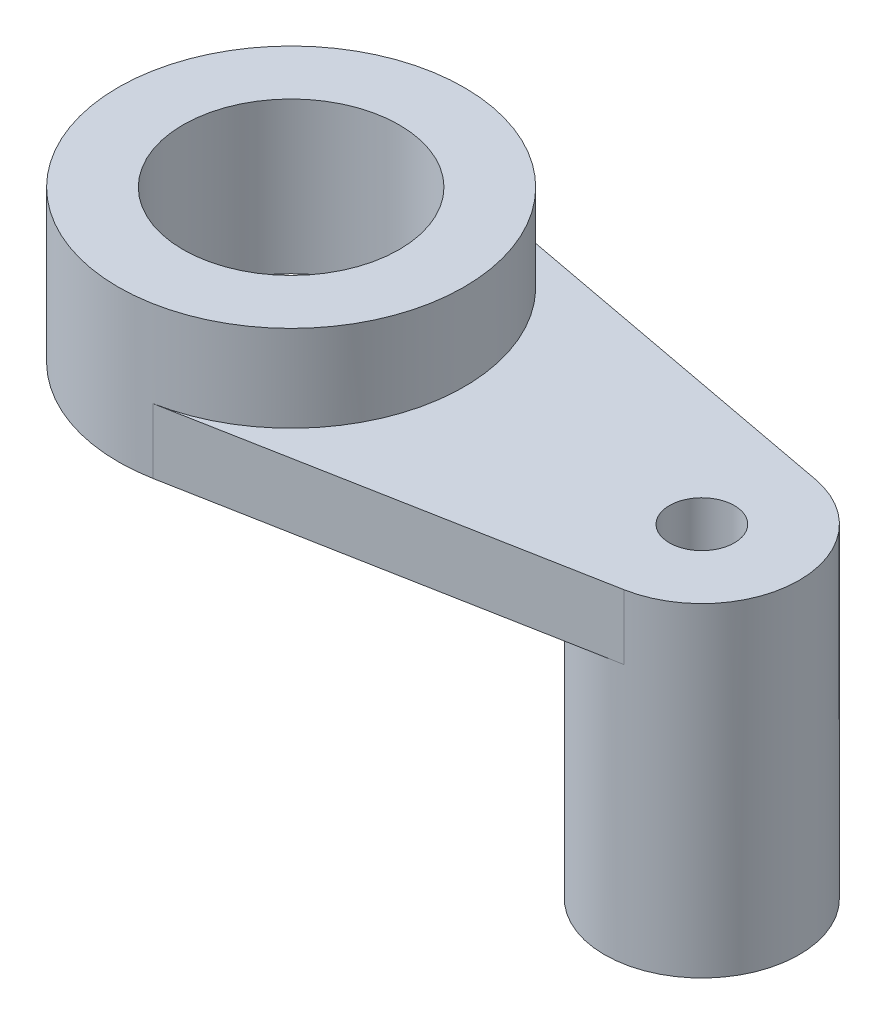
from build123d import *

# Parameters (mm, degrees)
SKETCH1_R           = 16
SKETCH1_R_2         = 10
BOSS_EXTRUDE1_DEPTH = 14
SKETCH1_3_R         = 9
SKETCH1_3_R_2       = 3
BOSS_EXTRUDE2_DEPTH = 6
SKETCH1_4_R         = 9
SKETCH1_4_R_2       = 3
BOSS_EXTRUDE3_DEPTH = 24


with BuildPart() as part:
    # Sketch1 → Boss-Extrude1 (new body)
    with BuildSketch(Plane(origin=(0, 0, 0), x_dir=(1, 0, 0), z_dir=(0, 1, 0))):
        with Locations(Location((-37.734018866, 0, 0), (0, 0, 270))):
            Circle(SKETCH1_R)
        with Locations(Location((-37.734018866, 0, 0), (0, 0, 270))):
            Circle(SKETCH1_R_2, mode=Mode.SUBTRACT)
    extrude(amount=BOSS_EXTRUDE1_DEPTH)

    # Sketch1_3 → Boss-Extrude2 (add)
    with BuildSketch(Plane(origin=(0, 0, 0), x_dir=(1, 0, 0), z_dir=(0, 1, 0))):
        with BuildLine():
            Line((1.923875508, 8.845981361), (-34.786650445, 15.726188966))
            ThreePointArc((-34.786650445, 15.726188966), (-25.422278641, 10.218661979), (-21.734018866, 0))
            ThreePointArc((-21.734018866, 0), (-25.422278641, -10.218661979), (-34.786650445, -15.726188966))
            Line((-34.786650445, -15.726188966), (1.923875871, -8.845981293))
            ThreePointArc((1.923875871, -8.845981293), (-8.734018866, -1.84e-07), (1.923875508, 8.845981361))
        make_face()
        with Locations((0.265981134, 0)):
            Circle(SKETCH1_3_R)
        with Locations(Location((0.265981134, 0, 0), (0, 0, 270))):
            Circle(SKETCH1_3_R_2, mode=Mode.SUBTRACT)
    extrude(amount=BOSS_EXTRUDE2_DEPTH)

    # Sketch1_4 → Boss-Extrude3 (add)
    with BuildSketch(Plane(origin=(0, 0, 0), x_dir=(1, 0, 0), z_dir=(0, 1, 0))):
        with Locations(Location((0.265981134, 0, 0), (0, 0, 79.384892149))):
            Circle(SKETCH1_4_R)
        with Locations(Location((0.265981134, 0, 0), (0, 0, 270))):
            Circle(SKETCH1_4_R_2, mode=Mode.SUBTRACT)
    extrude(amount=-BOSS_EXTRUDE3_DEPTH)


solid = part.part
